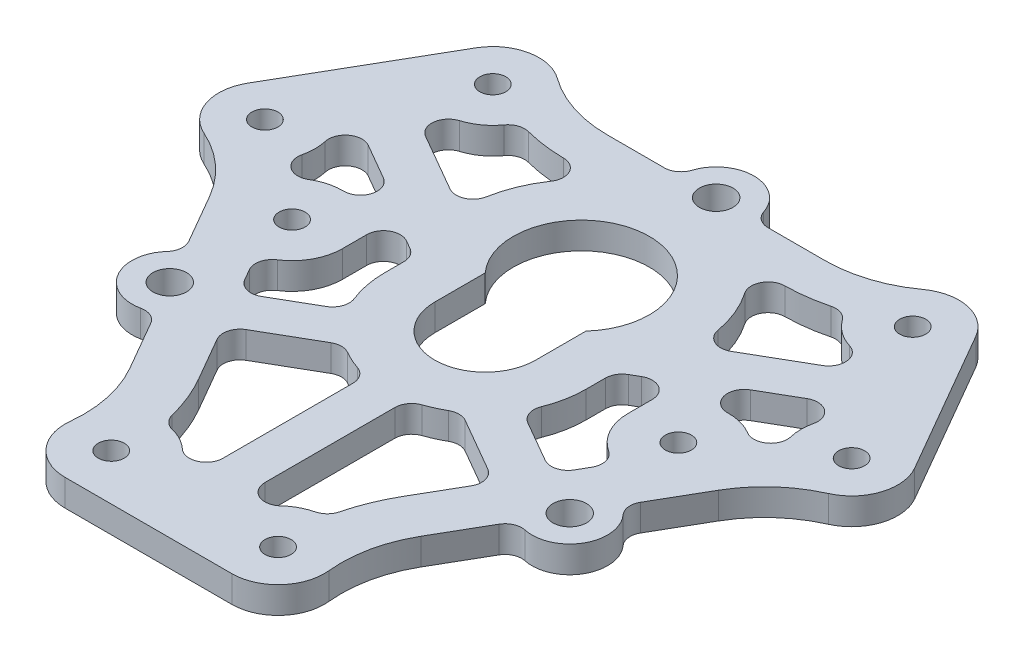
from build123d import *

# Parameters (mm, degrees)
SKETCH1_R           = 1.55
BOSS_EXTRUDE1_DEPTH = 3.175
BOSS_EXTRUDE2_DEPTH = 3.175
SKETCH6_3_R         = 2
CUT_EXTRUDE1_DEPTH  = 3.175
CUT_EXTRUDE2_DEPTH  = 3.175


with BuildPart() as part:
    # Sketch1 → Boss-Extrude1 (new body)
    with BuildSketch(Plane(origin=(0, 0, 0), x_dir=(1, 0, 0), z_dir=(0, 1, 0))):
        with BuildLine():
            Line((12.96622445, 27.5), (-12.96622445, 27.5))
            ThreePointArc((-12.96622445, 27.5), (-17.594676309, 28.231943602), (-21.771426072, 30.356342215))
            ThreePointArc((-21.771426072, 30.356342215), (-26.14607948, 31.282933613), (-29.763139721, 28.653667694))
            Line((-29.763139721, 28.653667694), (-39.696373995, 11.448801248))
            ThreePointArc((-39.696373995, 11.448801248), (-40.164854954, 7.001702233), (-37.17507656, 3.676436947))
            ThreePointArc((-37.17507656, 3.676436947), (-33.246918512, 1.121464854), (-30.298810829, -2.520920235))
            Line((-30.298810829, -2.520920235), (-17.332586379, -24.979079765))
            ThreePointArc((-17.332586379, -24.979079765), (-15.652242203, -29.353408456), (-15.403650488, -34.032779162))
            ThreePointArc((-15.403650488, -34.032779162), (-14.018775474, -38.284635845), (-9.933234274, -40.102468942))
            Line((-9.933234274, -40.102468942), (9.933234274, -40.102468942))
            ThreePointArc((9.933234274, -40.102468942), (14.018775474, -38.284635845), (15.403650488, -34.032779162))
            ThreePointArc((15.403650488, -34.032779162), (15.652242203, -29.353408456), (17.332586379, -24.979079765))
            Line((17.332586379, -24.979079765), (30.298810829, -2.520920235))
            ThreePointArc((30.298810829, -2.520920235), (33.246918512, 1.121464854), (37.17507656, 3.676436947))
            ThreePointArc((37.17507656, 3.676436947), (40.164854954, 7.001702233), (39.696373995, 11.448801248))
            Line((39.696373995, 11.448801248), (29.763139721, 28.653667694))
            ThreePointArc((29.763139721, 28.653667694), (26.14607948, 31.282933613), (21.771426072, 30.356342215))
            ThreePointArc((21.771426072, 30.356342215), (17.594676309, 28.231943602), (12.96622445, 27.5))
        make_face()
        with Locations((-9.933234274, -34.602468942)):
            Circle(SKETCH1_R, mode=Mode.SUBTRACT)
        with Locations((9.933234274, -34.602468942)):
            Circle(SKETCH1_R, mode=Mode.SUBTRACT)
        with Locations((-23, 0)):
            Circle(SKETCH1_R, mode=Mode.SUBTRACT)
        with Locations((-34.933234274, 8.698801248)):
            Circle(SKETCH1_R, mode=Mode.SUBTRACT)
        with BuildLine():
            ThreePointArc((6, 0), (0, -6), (-6, 0))
            Line((-6, 0), (-6, 6))
            ThreePointArc((-6, 6), (0, 19.541507144), (6, 6))
            Line((6, 6), (6, 0))
        make_face(mode=Mode.SUBTRACT)
        with Locations((-25, 25.903667694)):
            Circle(SKETCH1_R, mode=Mode.SUBTRACT)
        with Locations((23, 0)):
            Circle(SKETCH1_R, mode=Mode.SUBTRACT)
        with Locations((34.933234274, 8.698801248)):
            Circle(SKETCH1_R, mode=Mode.SUBTRACT)
        with Locations((25, 25.903667694)):
            Circle(SKETCH1_R, mode=Mode.SUBTRACT)
    extrude(amount=BOSS_EXTRUDE1_DEPTH)

    # Sketch6 → Boss-Extrude2 (add)
    with BuildSketch(Plane(origin=(0, 3.175, 0), x_dir=(1, 0, 0), z_dir=(0, 1, 0))):
        with BuildLine():
            ThreePointArc((-2, 27.5), (0, 29.5), (2, 27.5))
            Line((2, 27.5), (6.184658438, 27.5))
            ThreePointArc((6.184658438, 27.5), (5.007961628, 27.88278492), (4.281686611, 28.884615385))
            ThreePointArc((4.281686611, 28.884615385), (0, 32), (-4.281686611, 28.884615385))
            ThreePointArc((-4.281686611, 28.884615385), (-5.007961628, 27.88278492), (-6.184658438, 27.5))
            Line((-6.184658438, 27.5), (-2, 27.5))
        make_face()
        with BuildLine():
            ThreePointArc((-22.815698604, -15.482050808), (-25.547749412, -14.75), (-24.815698604, -12.017949192))
            Line((-24.815698604, -12.017949192), (-26.908027823, -8.393928679))
            ThreePointArc((-26.908027823, -8.393928679), (-26.651180883, -9.604370469), (-27.155654007, -10.734258316))
            ThreePointArc((-27.155654007, -10.734258316), (-27.712812921, -16), (-22.873967396, -18.150357069))
            ThreePointArc((-22.873967396, -18.150357069), (-21.643219255, -18.278414451), (-20.723369385, -19.106071321))
            Line((-20.723369385, -19.106071321), (-22.815698604, -15.482050808))
        make_face()
        with BuildLine():
            ThreePointArc((25.815698604, -13.75), (24.815698604, -15.482050808), (22.815698604, -15.482050808))
            Line((22.815698604, -15.482050808), (20.723369385, -19.106071321))
            ThreePointArc((20.723369385, -19.106071321), (21.643219255, -18.278414451), (22.873967396, -18.150357069))
            ThreePointArc((22.873967396, -18.150357069), (27.712812921, -16), (27.155654007, -10.734258316))
            ThreePointArc((27.155654007, -10.734258316), (26.651180883, -9.604370469), (26.908027823, -8.393928679))
            Line((26.908027823, -8.393928679), (24.815698604, -12.017949192))
            ThreePointArc((24.815698604, -12.017949192), (25.547749412, -12.75), (25.815698604, -13.75))
        make_face()
    extrude(amount=-BOSS_EXTRUDE2_DEPTH)

    # Sketch6_3 → Cut-Extrude1 (cut)
    with BuildSketch(Plane(origin=(0, 3.175, 0), x_dir=(1, 0, 0), z_dir=(0, 1, 0))):
        with Locations((0, 27.5)):
            Circle(SKETCH6_3_R)
        with Locations((23.815698604, -13.75)):
            Circle(SKETCH6_3_R)
        with Locations((-23.815698604, -13.75)):
            Circle(SKETCH6_3_R)
    extrude(amount=-CUT_EXTRUDE1_DEPTH, mode=Mode.SUBTRACT)

    # Sketch8 → Cut-Extrude2 (cut)
    with BuildSketch(Plane(origin=(0, 3.175, 0), x_dir=(1, 0, 0), z_dir=(0, 1, 0))):
        with BuildLine():
            ThreePointArc((-18.014934082, 23.14772543), (-15.611227846, 22.675672596), (-13.167842343, 22.50101627))
            ThreePointArc((-13.167842343, 22.50101627), (-11.413458512, 21.423607919), (-11.539503616, 19.368666553))
            ThreePointArc((-11.539503616, 19.368666553), (-12.946902958, 16.768579867), (-13.776895286, 13.930915965))
            ThreePointArc((-13.776895286, 13.930915965), (-14.903624597, 12.472145505), (-16.745023184, 12.554494989))
            Line((-16.745023184, 12.554494989), (-23.63134684, 16.530315806))
            ThreePointArc((-23.63134684, 16.530315806), (-24.618926237, 18.484915802), (-23.22351013, 20.172691883))
            ThreePointArc((-23.22351013, 20.172691883), (-21.502124547, 21.028745406), (-20.139853784, 22.385290403))
            ThreePointArc((-20.139853784, 22.385290403), (-19.195254644, 23.094987771), (-18.014934082, 23.14772543))
        make_face()
        with BuildLine():
            ThreePointArc((-29.097842321, 7.303021627), (-28.933338172, 8.663491751), (-29.081818699, 10.025803796))
            ThreePointArc((-29.081818699, 10.025803796), (-28.31786979, 12.078157634), (-26.13134684, 12.200188787))
            Line((-26.13134684, 12.200188787), (-21.854101966, 9.730720307))
            ThreePointArc((-21.854101966, 9.730720307), (-20.927050983, 7.463436365), (-22.890576475, 5.999002125))
            ThreePointArc((-22.890576475, 5.999002125), (-24.564350708, 5.792478473), (-26.114533752, 5.128321315))
            ThreePointArc((-26.114533752, 5.128321315), (-28.330833555, 5.221584528), (-29.097842321, 7.303021627))
        make_face()
        with BuildLine():
            ThreePointArc((-17, 2.886751346), (-16, 4.618802154), (-14, 4.618802154))
            Line((-14, 4.618802154), (-13, 4.041451884))
            ThreePointArc((-13, 4.041451884), (-12.267949192, 3.309401077), (-12, 2.309401077))
            Line((-12, 2.309401077), (-12, 0))
            ThreePointArc((-12, 0), (-11.783766073, -2.267786838), (-11.142857143, -4.453844934))
            ThreePointArc((-11.142857143, -4.453844934), (-11.110177635, -5.850806093), (-12, -6.92820323))
            Line((-12, -6.92820323), (-16.887495374, -9.75))
            ThreePointArc((-16.887495374, -9.75), (-18.405133464, -9.949800845), (-19.619546181, -9.017949192))
            Line((-19.619546181, -9.017949192), (-20.375025334, -7.709420916))
            ThreePointArc((-20.375025334, -7.709420916), (-20.587711347, -6.242517607), (-19.732230895, -5.032065687))
            ThreePointArc((-19.732230895, -5.032065687), (-17.727115845, -2.862986672), (-17, 0))
            Line((-17, 0), (-17, 2.886751346))
        make_face()
        with BuildLine():
            ThreePointArc((-5.858308569, -30.198495679), (-7.090344692, -29.318722276), (-8.503371348, -28.775334825))
            ThreePointArc((-8.503371348, -28.775334825), (-9.435726866, -28.252388095), (-9.965551857, -27.323924002))
            ThreePointArc((-9.965551857, -27.323924002), (-10.866584364, -24.576601814), (-12.136433956, -21.979079765))
            Line((-12.136433956, -21.979079765), (-15.119546181, -16.812177826))
            ThreePointArc((-15.119546181, -16.812177826), (-15.319347026, -15.294539736), (-14.387495374, -14.080127019))
            Line((-14.387495374, -14.080127019), (-8, -10.392304845))
            ThreePointArc((-8, -10.392304845), (-7, -10.124355653), (-6, -10.392304845))
            ThreePointArc((-6, -10.392304845), (-4.952421484, -10.930394387), (-3.857142857, -11.363205929))
            ThreePointArc((-3.857142857, -11.363205929), (-2.874313332, -12.092108839), (-2.5, -13.257073584))
            Line((-2.5, -13.257073584), (-2.5, -28.730504592))
            ThreePointArc((-2.5, -28.730504592), (-3.698943553, -30.563073436), (-5.858308569, -30.198495679))
        make_face()
        with BuildLine():
            ThreePointArc((6, -10.392304845), (4.952421484, -10.930394387), (3.857142857, -11.363205929))
            ThreePointArc((3.857142857, -11.363205929), (2.874313332, -12.092108839), (2.5, -13.257073584))
            Line((2.5, -13.257073584), (2.5, -28.730504592))
            ThreePointArc((2.5, -28.730504592), (3.698943553, -30.563073436), (5.858308569, -30.198495679))
            ThreePointArc((5.858308569, -30.198495679), (7.090344692, -29.318722276), (8.503371348, -28.775334825))
            ThreePointArc((8.503371348, -28.775334825), (9.435726866, -28.252388095), (9.965551857, -27.323924002))
            ThreePointArc((9.965551857, -27.323924002), (10.866584364, -24.576601814), (12.136433956, -21.979079765))
            Line((12.136433956, -21.979079765), (15.119546181, -16.812177826))
            ThreePointArc((15.119546181, -16.812177826), (15.319347026, -15.294539736), (14.387495374, -14.080127019))
            Line((14.387495374, -14.080127019), (8, -10.392304845))
            ThreePointArc((8, -10.392304845), (7, -10.124355653), (6, -10.392304845))
        make_face()
        with BuildLine():
            Line((14, 4.618802154), (13, 4.041451884))
            ThreePointArc((13, 4.041451884), (12.267949192, 3.309401077), (12, 2.309401077))
            Line((12, 2.309401077), (12, 0))
            ThreePointArc((12, 0), (11.783766073, -2.267786838), (11.142857143, -4.453844934))
            ThreePointArc((11.142857143, -4.453844934), (11.110177635, -5.850806093), (12, -6.92820323))
            Line((12, -6.92820323), (16.887495374, -9.75))
            ThreePointArc((16.887495374, -9.75), (18.405133464, -9.949800845), (19.619546181, -9.017949192))
            Line((19.619546181, -9.017949192), (20.375025334, -7.709420916))
            ThreePointArc((20.375025334, -7.709420916), (20.587711347, -6.242517607), (19.732230895, -5.032065687))
            ThreePointArc((19.732230895, -5.032065687), (17.727115845, -2.862986672), (17, 0))
            Line((17, 0), (17, 2.886751346))
            ThreePointArc((17, 2.886751346), (16, 4.618802154), (14, 4.618802154))
        make_face()
        with BuildLine():
            ThreePointArc((22.890576475, 5.999002125), (20.927050983, 7.463436365), (21.854101966, 9.730720307))
            Line((21.854101966, 9.730720307), (26.13134684, 12.200188787))
            ThreePointArc((26.13134684, 12.200188787), (28.31786979, 12.078157634), (29.081818699, 10.025803796))
            ThreePointArc((29.081818699, 10.025803796), (28.933338172, 8.663491751), (29.097842321, 7.303021627))
            ThreePointArc((29.097842321, 7.303021627), (28.330833555, 5.221584528), (26.114533752, 5.128321315))
            ThreePointArc((26.114533752, 5.128321315), (24.564350708, 5.792478473), (22.890576475, 5.999002125))
        make_face()
        with BuildLine():
            ThreePointArc((11.539503616, 19.368666553), (11.413458512, 21.423607919), (13.167842343, 22.50101627))
            ThreePointArc((13.167842343, 22.50101627), (15.611227846, 22.675672596), (18.014934082, 23.14772543))
            ThreePointArc((18.014934082, 23.14772543), (19.195254644, 23.094987771), (20.139853784, 22.385290403))
            ThreePointArc((20.139853784, 22.385290403), (21.502124547, 21.028745406), (23.22351013, 20.172691883))
            ThreePointArc((23.22351013, 20.172691883), (24.618926237, 18.484915802), (23.63134684, 16.530315806))
            Line((23.63134684, 16.530315806), (16.745023184, 12.554494989))
            ThreePointArc((16.745023184, 12.554494989), (14.903624597, 12.472145505), (13.776895286, 13.930915965))
            ThreePointArc((13.776895286, 13.930915965), (12.946902958, 16.768579867), (11.539503616, 19.368666553))
        make_face()
    extrude(amount=-CUT_EXTRUDE2_DEPTH, mode=Mode.SUBTRACT)


solid = part.part
